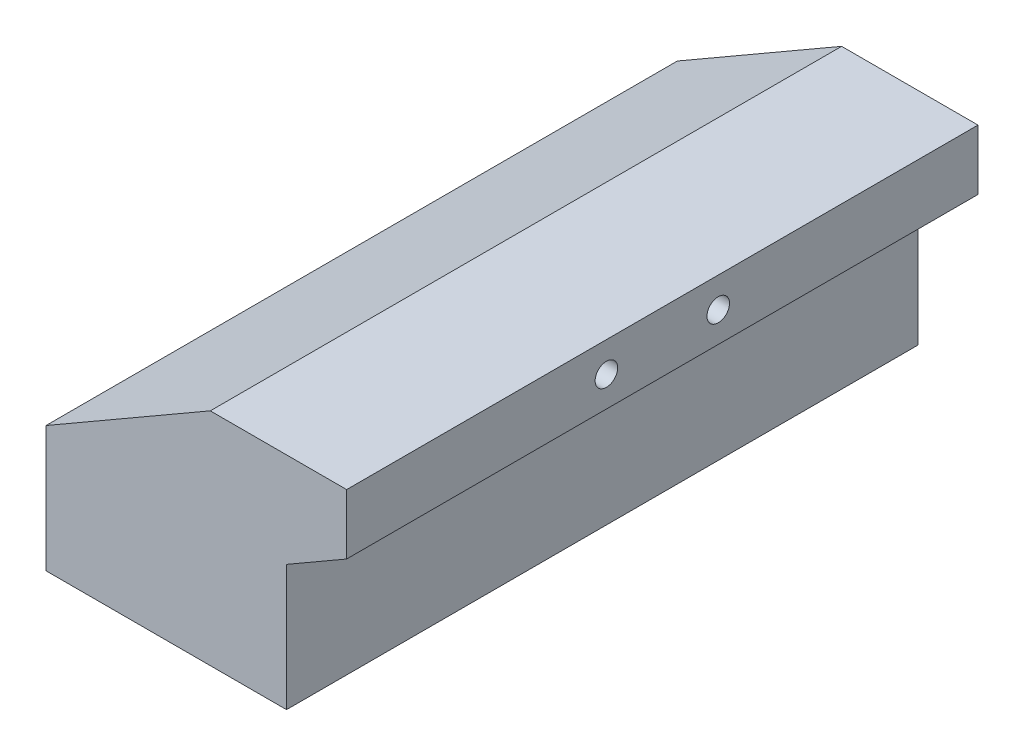
from build123d import *

# Parameters (mm, degrees)
SKETCH1_W           = 50.8
SKETCH1_H           = 26.576651581
BOSS_EXTRUDE1_DEPTH = 66.675
SKETCH3_R           = 2.38125
CUT_EXTRUDE1_DEPTH  = 9.525


with BuildPart() as part:
    # Sketch1 → Boss-Extrude1 (new body, symmetric)
    with BuildSketch(Plane.XY):
        with Locations((25.4, 13.288325791)):
            Rectangle(SKETCH1_W, SKETCH1_H)
        Polygon((34.697045256, 46.609), (0, 26.576651581), (50.8, 26.576651581), (63.5, 33.909), (63.5, 46.609), align=None)
    extrude(amount=BOSS_EXTRUDE1_DEPTH, both=True)

    # Sketch3 → Cut-Extrude1 (cut)
    with BuildSketch(Plane(origin=(63.5, 0, 0), x_dir=(0, 0, -1), z_dir=(1, 0, 0))):
        with Locations((-11.811, 40.259)):
            Circle(SKETCH3_R)
        with Locations((11.811, 40.259)):
            Circle(SKETCH3_R)
    extrude(amount=-CUT_EXTRUDE1_DEPTH, mode=Mode.SUBTRACT)


solid = part.part
